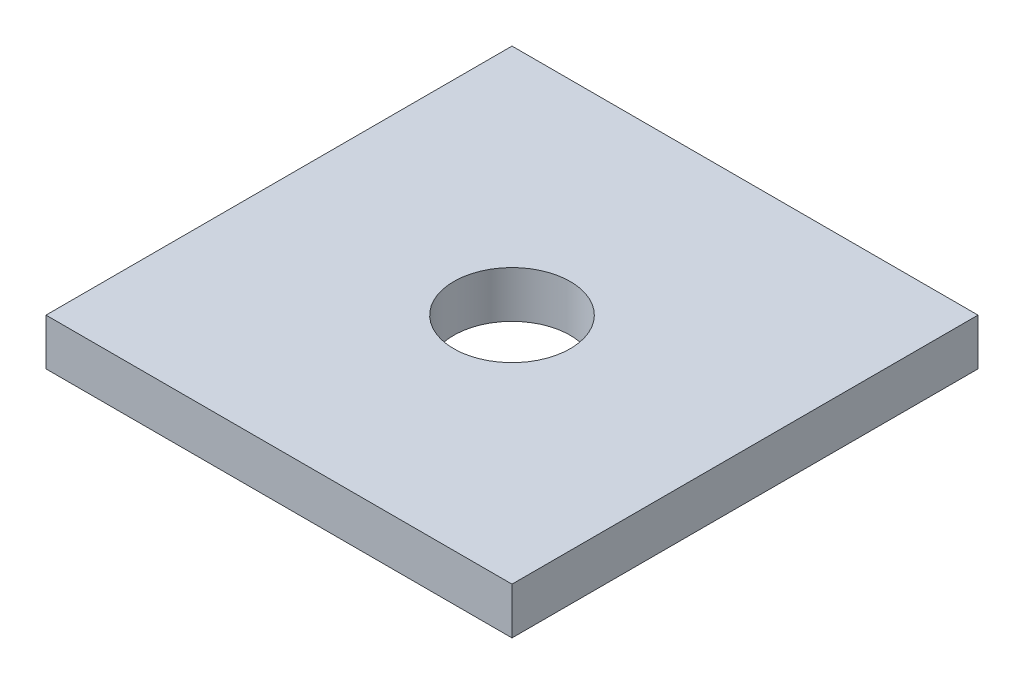
from build123d import *

# Parameters (mm, degrees)
SKETCH1_W           = 25.4
SKETCH1_H           = 25.4
BOSS_EXTRUDE1_DEPTH = 2.54
SKETCH2_R           = 3.175
CUT_EXTRUDE1_DEPTH  = 2.54


with BuildPart() as part:
    # Sketch1 → Boss-Extrude1 (new body)
    with BuildSketch(Plane(origin=(0, 0, 0), x_dir=(1, 0, 0), z_dir=(0, 1, 0))):
        with Locations((12.7, 12.7)):
            Rectangle(SKETCH1_W, SKETCH1_H)
    extrude(amount=BOSS_EXTRUDE1_DEPTH)

    # Sketch2 → Cut-Extrude1 (cut)
    with BuildSketch(Plane(origin=(0, 2.54, 0), x_dir=(1, 0, 0), z_dir=(0, 1, 0))):
        with Locations((12.7, 12.7)):
            Circle(SKETCH2_R)
    extrude(amount=-CUT_EXTRUDE1_DEPTH, mode=Mode.SUBTRACT)


solid = part.part
